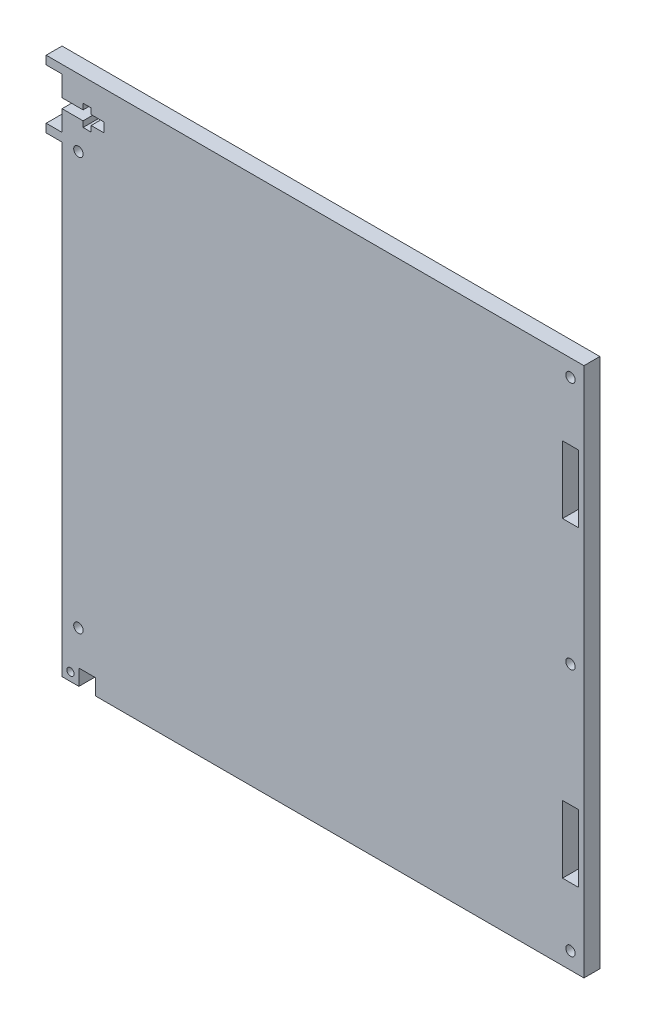
from build123d import *

# Parameters (mm, degrees)
SKETCH1_W           = 196.85
SKETCH1_H           = 200.025
BOSS_EXTRUDE1_DEPTH = 5.9944
SKETCH2_R           = 1.778
SKETCH2_R_2         = 1.35255
SKETCH2_W           = 5.9944
SKETCH2_H           = 25.4
SKETCH2_W_2         = 6.35
SKETCH2_H_2         = 5.9944
CUT_EXTRUDE1_DEPTH  = 6.9944
SKETCH3_W           = 5.9944
SKETCH3_H           = 3.175
BOSS_EXTRUDE2_DEPTH = 5.9944


with BuildPart() as part:
    # Sketch1 → Boss-Extrude1 (new body)
    with BuildSketch(Plane.XY):
        with Locations((98.425, 100.0125)):
            Rectangle(SKETCH1_W, SKETCH1_H)
    extrude(amount=-BOSS_EXTRUDE1_DEPTH)

    # Sketch2 → Cut-Extrude1 (cut, through all)
    with BuildSketch(Plane.XY):
        with Locations((191.77, 193.675)):
            Circle(SKETCH2_R)
        with Locations((191.77, 100.0125)):
            Circle(SKETCH2_R)
        with Locations((191.77, 6.35)):
            Circle(SKETCH2_R)
        with Locations((3.175, 3.175)):
            Circle(SKETCH2_R_2)
        with Locations((6.1722, 174.625)):
            Circle(SKETCH2_R)
        with Locations((6.1722, 19.05)):
            Circle(SKETCH2_R)
        with Locations((191.77, 158.75)):
            Rectangle(SKETCH2_W, SKETCH2_H)
        with Locations((191.77, 41.275)):
            Rectangle(SKETCH2_W, SKETCH2_H)
        Polygon((7.9248, 189.103), (7.9248, 191.2874), (10.9728, 191.2874), (10.9728, 189.103), (15.875, 189.103), (15.875, 185.547), (10.9728, 185.547), (10.9728, 183.3626), (7.9248, 183.3626), (7.9248, 185.547), (0, 185.547), (0, 189.103), align=None)
        with Locations((9.525, 2.9972)):
            Rectangle(SKETCH2_W_2, SKETCH2_H_2)
    extrude(amount=-CUT_EXTRUDE1_DEPTH, mode=Mode.SUBTRACT)

    # Sketch3 → Boss-Extrude2 (add)
    with BuildSketch(Plane.XY):
        with Locations((-2.9972, 198.4375)):
            Rectangle(SKETCH3_W, SKETCH3_H)
        with Locations((-2.9972, 176.2125)):
            Rectangle(SKETCH3_W, SKETCH3_H)
    extrude(amount=-BOSS_EXTRUDE2_DEPTH)


solid = part.part
